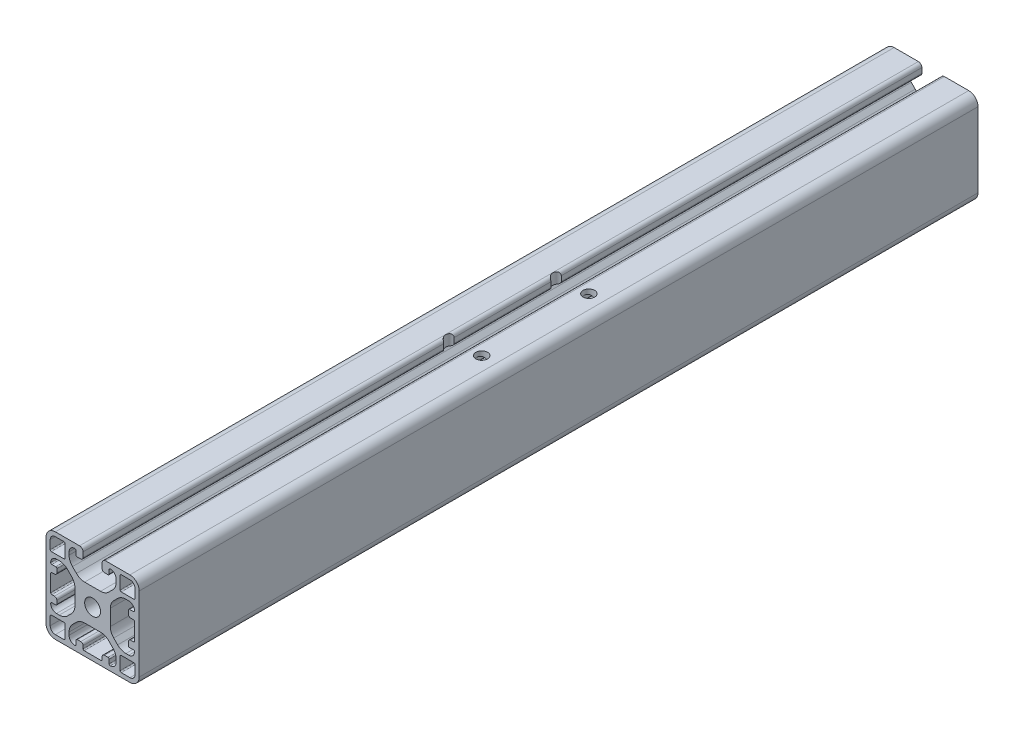
from build123d import *

# Parameters (mm, degrees)
SKIZZE1_R                       = 3.4
AUFSATZ_LINEAR_AUSTRAGEN1_DEPTH = 360
M6_GEWINDEBOHRUNG1_D            = 5


with BuildPart() as part:
    # Skizze1 → Aufsatz-Linear austragen1 (new body)
    with BuildSketch(Plane.XY.offset(1000)):
        with BuildLine():
            Line((23.100000014, 35.850000004), (23.100000014, 37.500000007))
            ThreePointArc((23.100000014, 37.500000007), (23.246446625, 37.8535534), (23.600000018, 38.000000007))
            ThreePointArc((23.600000018, 38.000000007), (25.367766957, 37.267766953), (26.099999996, 35.500000007))
            Line((26.099999996, 35.500000007), (26.099999996, 34.292388137))
            ThreePointArc((26.099999996, 34.292388137), (25.719397659, 32.378970975), (24.635533902, 30.756854231))
            Line((24.635533902, 30.756854231), (22.943145774, 29.064466103))
            ThreePointArc((22.943145774, 29.064466103), (21.32102903, 27.980602346), (19.407611868, 27.600000008))
            Line((19.407611868, 27.600000008), (12.592388142, 27.600000008))
            ThreePointArc((12.592388142, 27.600000008), (10.678970981, 27.980602346), (9.056854237, 29.064466102))
            Line((9.056854237, 29.064466102), (7.36446608, 30.75685426))
            ThreePointArc((7.36446608, 30.75685426), (6.280602323, 32.378971004), (5.899999986, 34.292388165))
            Line((5.899999986, 34.292388165), (5.899999986, 35.500000003))
            ThreePointArc((5.899999986, 35.500000003), (6.632233037, 37.267766961), (8.399999999, 38.000000003))
            ThreePointArc((8.399999999, 38.000000003), (8.753553388, 37.853553393), (8.899999996, 37.500000003))
            Line((8.899999996, 37.500000003), (8.899999996, 35.850000004))
            ThreePointArc((8.899999996, 35.850000004), (9.046446605, 35.496446613), (9.399999996, 35.350000004))
            Line((9.399999996, 35.350000004), (10.899999944, 35.350000004))
            ThreePointArc((10.899999944, 35.350000004), (11.607106725, 35.642893223), (11.899999944, 36.350000004))
            Line((11.899999944, 36.350000004), (11.899999944, 38.500000016))
            ThreePointArc((11.899999944, 38.500000016), (11.460660115, 39.560660188), (10.399999943, 40.000000016))
            Line((10.399999943, 40.000000016), (4.8e-08, 40.000000016))
            ThreePointArc((4.8e-08, 40.000000016), (-2.828427121, 38.828427123), (-4.000000014, 35.999999954))
            Line((-4.000000014, 35.999999954), (-4.000000014, 4.000000069))
            ThreePointArc((-4.000000014, 4.000000069), (-2.828427124, 1.171572908), (3.7e-08, 1.8e-08))
            Line((3.7e-08, 1.8e-08), (31.999999922, 1.8e-08))
            ThreePointArc((31.999999922, 1.8e-08), (34.828427083, 1.171572908), (35.999999974, 4.000000069))
            Line((35.999999974, 4.000000069), (35.999999974, 35.999999953))
            ThreePointArc((35.999999974, 35.999999953), (34.82842708, 38.828427122), (31.99999991, 40.000000016))
            Line((31.99999991, 40.000000016), (21.599999961, 40.000000016))
            ThreePointArc((21.599999961, 40.000000016), (20.53933979, 39.560660188), (20.099999962, 38.500000017))
            Line((20.099999962, 38.500000017), (20.099999962, 36.350000004))
            ThreePointArc((20.099999962, 36.350000004), (20.392893181, 35.642893223), (21.099999962, 35.350000004))
            Line((21.099999962, 35.350000004), (22.600000014, 35.350000004))
            ThreePointArc((22.600000014, 35.350000004), (22.953553405, 35.496446613), (23.100000014, 35.850000004))
        make_face()
        with Locations((15.999999985, 20)):
            Circle(SKIZZE1_R, mode=Mode.SUBTRACT)
        with BuildLine():
            Line((4.8e-08, 38.200000033), (3.699999945, 38.200000033))
            ThreePointArc((3.699999945, 38.200000033), (4.053553343, 38.053553421), (4.199999956, 37.700000022))
            Line((4.199999956, 37.700000022), (4.199999956, 32.299999708))
            ThreePointArc((4.199999956, 32.299999708), (4.053553442, 31.946446549), (3.700000282, 31.800000035))
            Line((3.700000282, 31.800000035), (-1.70000008, 31.800000035))
            ThreePointArc((-1.70000008, 31.800000035), (-2.053553436, 31.94644663), (-2.200000031, 32.299999986))
            Line((-2.200000031, 32.299999986), (-2.200000031, 35.999999954))
            ThreePointArc((-2.200000031, 35.999999954), (-1.555634927, 37.555634929), (4.8e-08, 38.200000033))
        make_face(mode=Mode.SUBTRACT)
        with BuildLine():
            Line((-2.200000031, 4.000000069), (-2.200000031, 7.699999986))
            ThreePointArc((-2.200000031, 7.699999986), (-2.053553419, 8.053553385), (-1.70000002, 8.199999998))
            Line((-1.70000002, 8.199999998), (3.700000282, 8.199999998))
            ThreePointArc((3.700000282, 8.199999998), (4.053553442, 8.053553484), (4.199999956, 7.700000324))
            Line((4.199999956, 7.700000324), (4.199999956, 2.299999952))
            ThreePointArc((4.199999956, 2.299999952), (4.053553361, 1.946446596), (3.700000004, 1.800000001))
            Line((3.700000004, 1.800000001), (3.7e-08, 1.800000001))
            ThreePointArc((3.7e-08, 1.800000001), (-1.55563493, 2.444365102), (-2.200000031, 4.000000069))
        make_face(mode=Mode.SUBTRACT)
        with BuildLine():
            Line((31.999999922, 1.800000001), (28.300000004, 1.800000001))
            ThreePointArc((28.300000004, 1.800000001), (27.946446606, 1.946446613), (27.799999993, 2.300000012))
            Line((27.799999993, 2.300000012), (27.799999993, 7.700000324))
            ThreePointArc((27.799999993, 7.700000324), (27.946446507, 8.053553484), (28.299999667, 8.199999998))
            Line((28.299999667, 8.199999998), (33.700000039, 8.199999998))
            ThreePointArc((33.700000039, 8.199999998), (34.053553395, 8.053553402), (34.199999991, 7.700000046))
            Line((34.199999991, 7.700000046), (34.199999991, 4.000000069))
            ThreePointArc((34.199999991, 4.000000069), (33.555634889, 2.444365102), (31.999999922, 1.800000001))
        make_face(mode=Mode.SUBTRACT)
        with BuildLine():
            Line((34.199999991, 35.999999953), (34.199999991, 32.300000046))
            ThreePointArc((34.199999991, 32.300000046), (34.053553378, 31.946446648), (33.699999979, 31.800000035))
            Line((33.699999979, 31.800000035), (28.299999667, 31.800000035))
            ThreePointArc((28.299999667, 31.800000035), (27.946446507, 31.946446549), (27.799999993, 32.299999708))
            Line((27.799999993, 32.299999708), (27.799999993, 37.700000082))
            ThreePointArc((27.799999993, 37.700000082), (27.946446588, 38.053553438), (28.299999945, 38.200000033))
            Line((28.299999945, 38.200000033), (31.99999991, 38.200000033))
            ThreePointArc((31.99999991, 38.200000033), (33.555634886, 37.555634928), (34.199999991, 35.999999953))
        make_face(mode=Mode.SUBTRACT)
        with BuildLine():
            Line((12.592388143, 12.399999997), (19.407611847, 12.399999997))
            ThreePointArc((19.407611847, 12.399999997), (21.321029009, 12.01939766), (22.943145752, 10.935533904))
            Line((22.943145752, 10.935533904), (24.635533902, 9.243145754))
            ThreePointArc((24.635533902, 9.243145754), (25.719397659, 7.62102901), (26.099999996, 5.707611848))
            Line((26.099999996, 5.707611848), (26.099999996, 4.499999993))
            ThreePointArc((26.099999996, 4.499999993), (25.367766957, 2.732233048), (23.600000018, 1.999999995))
            ThreePointArc((23.600000018, 1.999999995), (23.246446625, 2.146446603), (23.100000014, 2.499999995))
            Line((23.100000014, 2.499999995), (23.100000014, 4.149999994))
            ThreePointArc((23.100000014, 4.149999994), (22.953553405, 4.503553383), (22.600000016, 4.649999992))
            Line((22.600000016, 4.649999992), (21.099999962, 4.649999992))
            ThreePointArc((21.099999962, 4.649999992), (20.392893181, 4.357106773), (20.099999962, 3.649999992))
            Line((20.099999962, 3.649999992), (20.099999962, 2.500000006))
            ThreePointArc((20.099999962, 2.500000006), (19.953553353, 2.146446616), (19.599999962, 2.000000006))
            Line((19.599999962, 2.000000006), (12.399999942, 2.000000006))
            ThreePointArc((12.399999942, 2.000000006), (12.046446553, 2.146446615), (11.899999944, 2.500000005))
            Line((11.899999944, 2.500000005), (11.899999944, 3.649999992))
            ThreePointArc((11.899999944, 3.649999992), (11.607106725, 4.357106773), (10.899999943, 4.649999992))
            Line((10.899999943, 4.649999992), (9.399999996, 4.649999992))
            ThreePointArc((9.399999996, 4.649999992), (9.046446606, 4.503553382), (8.899999996, 4.149999992))
            Line((8.899999996, 4.149999992), (8.899999996, 2.499999991))
            ThreePointArc((8.899999996, 2.499999991), (8.753553389, 2.146446604), (8.400000003, 1.999999994))
            ThreePointArc((8.400000003, 1.999999994), (6.632233039, 2.732233035), (5.899999986, 4.499999994))
            Line((5.899999986, 4.499999994), (5.899999986, 5.707611838))
            ThreePointArc((5.899999986, 5.707611838), (6.280602323, 7.621029001), (7.36446608, 9.243145746))
            Line((7.36446608, 9.243145746), (9.056854238, 10.935533903))
            ThreePointArc((9.056854238, 10.935533903), (10.678970982, 12.01939766), (12.592388143, 12.399999997))
        make_face(mode=Mode.SUBTRACT)
        with BuildLine():
            Line((-0.350000011, 15.899999977), (-1.500000012, 15.899999977))
            ThreePointArc((-1.500000012, 15.899999977), (-1.853553403, 16.046446586), (-2.000000012, 16.399999977))
            Line((-2.000000012, 16.399999977), (-2.000000012, 23.599999997))
            ThreePointArc((-2.000000012, 23.599999997), (-1.853553403, 23.953553386), (-1.500000014, 24.099999995))
            Line((-1.500000014, 24.099999995), (-0.350000011, 24.099999995))
            ThreePointArc((-0.350000011, 24.099999995), (0.35710677, 24.392893214), (0.649999989, 25.099999995))
            Line((0.649999989, 25.099999995), (0.649999989, 26.599999997))
            ThreePointArc((0.649999989, 26.599999997), (0.503553379, 26.953553388), (0.149999989, 27.099999997))
            Line((0.149999989, 27.099999997), (-1.500000012, 27.099999997))
            ThreePointArc((-1.500000012, 27.099999997), (-1.853553399, 27.246446604), (-2.000000009, 27.599999991))
            ThreePointArc((-2.000000009, 27.599999991), (-1.267766968, 29.367766955), (0.499999991, 30.100000008))
            Line((0.499999991, 30.100000008), (1.707611836, 30.100000008))
            ThreePointArc((1.707611836, 30.100000008), (3.621028998, 29.71939767), (5.243145743, 28.635533913))
            Line((5.243145743, 28.635533913), (6.935533893, 26.943145763))
            ThreePointArc((6.935533893, 26.943145763), (8.01939765, 25.321029019), (8.399999987, 23.407611857))
            Line((8.399999987, 23.407611857), (8.399999987, 16.592388128))
            ThreePointArc((8.399999987, 16.592388128), (8.01939765, 14.678970966), (6.935533894, 13.056854223))
            Line((6.935533894, 13.056854223), (5.243145736, 11.364466065))
            ThreePointArc((5.243145736, 11.364466065), (3.621028992, 10.280602309), (1.70761183, 9.899999971))
            Line((1.70761183, 9.899999971), (0.49999999, 9.899999971))
            ThreePointArc((0.49999999, 9.899999971), (-1.267766966, 10.632233022), (-2.000000008, 12.399999982))
            ThreePointArc((-2.000000008, 12.399999982), (-1.853553397, 12.753553371), (-1.500000008, 12.899999979))
            Line((-1.500000008, 12.899999979), (0.149999991, 12.899999979))
            ThreePointArc((0.149999991, 12.899999979), (0.50355338, 13.046446588), (0.649999989, 13.399999977))
            Line((0.649999989, 13.399999977), (0.649999989, 14.899999976))
            ThreePointArc((0.649999989, 14.899999976), (0.35710677, 15.607106758), (-0.350000011, 15.899999977))
        make_face(mode=Mode.SUBTRACT)
        with BuildLine():
            Line((23.599999999, 16.592388152), (23.599999999, 23.407611854))
            ThreePointArc((23.599999999, 23.407611854), (23.980602337, 25.321029015), (25.064466093, 26.943145759))
            Line((25.064466093, 26.943145759), (26.756854248, 28.635533914))
            ThreePointArc((26.756854248, 28.635533914), (28.378970992, 29.71939767), (30.292388154, 30.100000008))
            Line((30.292388154, 30.100000008), (31.49999999, 30.100000008))
            ThreePointArc((31.49999999, 30.100000008), (33.267766947, 29.367766956), (33.999999988, 27.599999994))
            ThreePointArc((33.999999988, 27.599999994), (33.853553377, 27.246446605), (33.499999988, 27.099999997))
            Line((33.499999988, 27.099999997), (31.849999989, 27.099999997))
            ThreePointArc((31.849999989, 27.099999997), (31.4964466, 26.953553388), (31.349999991, 26.6))
            Line((31.349999991, 26.6), (31.349999991, 25.099999995))
            ThreePointArc((31.349999991, 25.099999995), (31.64289321, 24.392893214), (32.349999991, 24.099999995))
            Line((32.349999991, 24.099999995), (33.499999986, 24.099999995))
            ThreePointArc((33.499999986, 24.099999995), (33.853553377, 23.953553386), (33.999999986, 23.599999995))
            Line((33.999999986, 23.599999995), (33.999999986, 16.399999975))
            ThreePointArc((33.999999986, 16.399999975), (33.853553377, 16.046446586), (33.499999988, 15.899999977))
            Line((33.499999988, 15.899999977), (32.349999991, 15.899999977))
            ThreePointArc((32.349999991, 15.899999977), (31.64289321, 15.607106758), (31.349999991, 14.899999977))
            Line((31.349999991, 14.899999977), (31.349999991, 13.39999998))
            ThreePointArc((31.349999991, 13.39999998), (31.496446601, 13.046446589), (31.849999991, 12.899999979))
            Line((31.849999991, 12.899999979), (33.499999992, 12.899999979))
            ThreePointArc((33.499999992, 12.899999979), (33.85355338, 12.753553372), (33.999999989, 12.399999985))
            ThreePointArc((33.999999989, 12.399999985), (33.267766947, 10.632233023), (31.499999989, 9.899999971))
            Line((31.499999989, 9.899999971), (30.292388181, 9.899999971))
            ThreePointArc((30.292388181, 9.899999971), (28.378971018, 10.280602309), (26.756854273, 11.364466066))
            Line((26.756854273, 11.364466066), (25.064466093, 13.056854246))
            ThreePointArc((25.064466093, 13.056854246), (23.980602337, 14.67897099), (23.599999999, 16.592388152))
        make_face(mode=Mode.SUBTRACT)
    extrude(amount=-AUFSATZ_LINEAR_AUSTRAGEN1_DEPTH)

    # M6 Gewindebohrung1 (through all)
    with Locations(Plane(origin=(0, 0, 0), x_dir=(-1, 0, 0), z_dir=(0, -1, 0))):
        with Locations((-25.999999922, -797), (-12.999999922, -797), (-25.999999922, -843), (-12.999999922, -843)):
            Hole(M6_GEWINDEBOHRUNG1_D / 2)


solid = part.part
